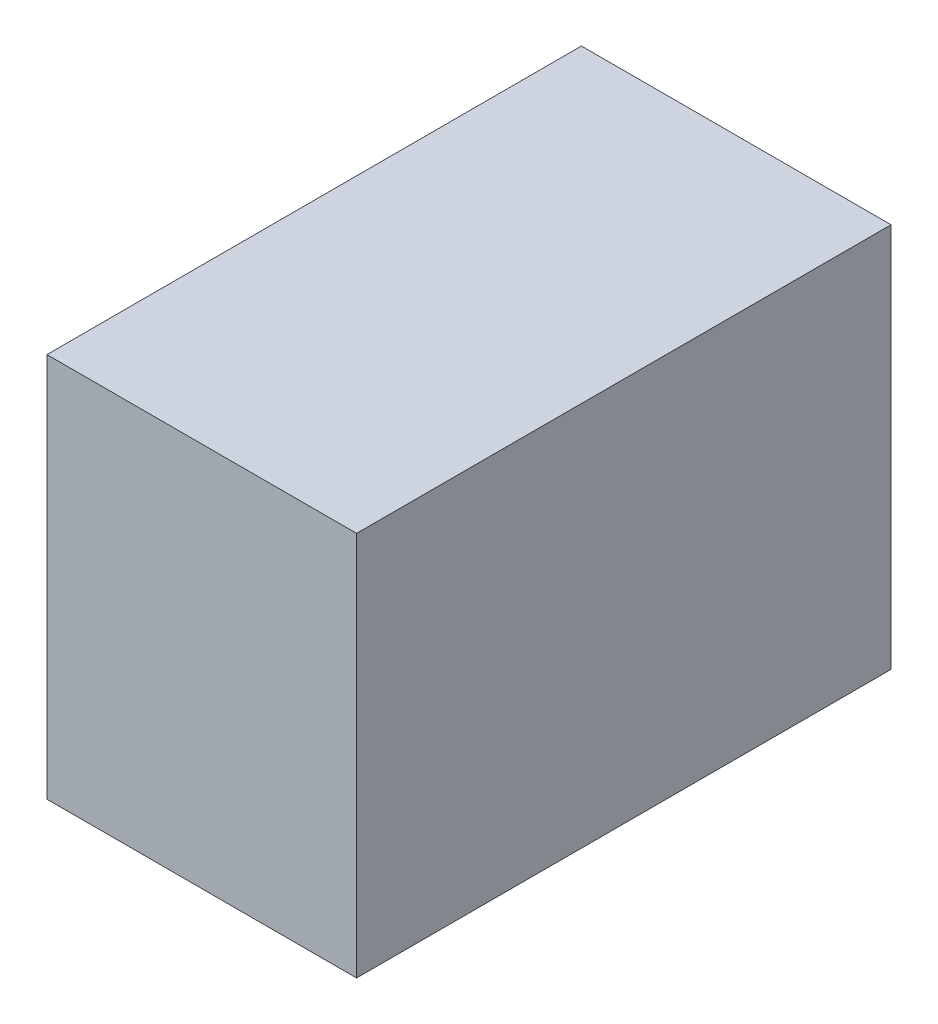
from build123d import *

# Parameters (mm, degrees)
SKETCH2_W           = 402.057823848
SKETCH2_H           = 694.029575014
BOSS_EXTRUDE1_DEPTH = 500


with BuildPart() as part:
    # Sketch2 → Boss-Extrude1 (new body)
    with BuildSketch(Plane(origin=(0, 0, 0), x_dir=(1, 0, 0), z_dir=(0, 1, 0))):
        Rectangle(SKETCH2_W, SKETCH2_H)
    extrude(amount=BOSS_EXTRUDE1_DEPTH)


solid = part.part
